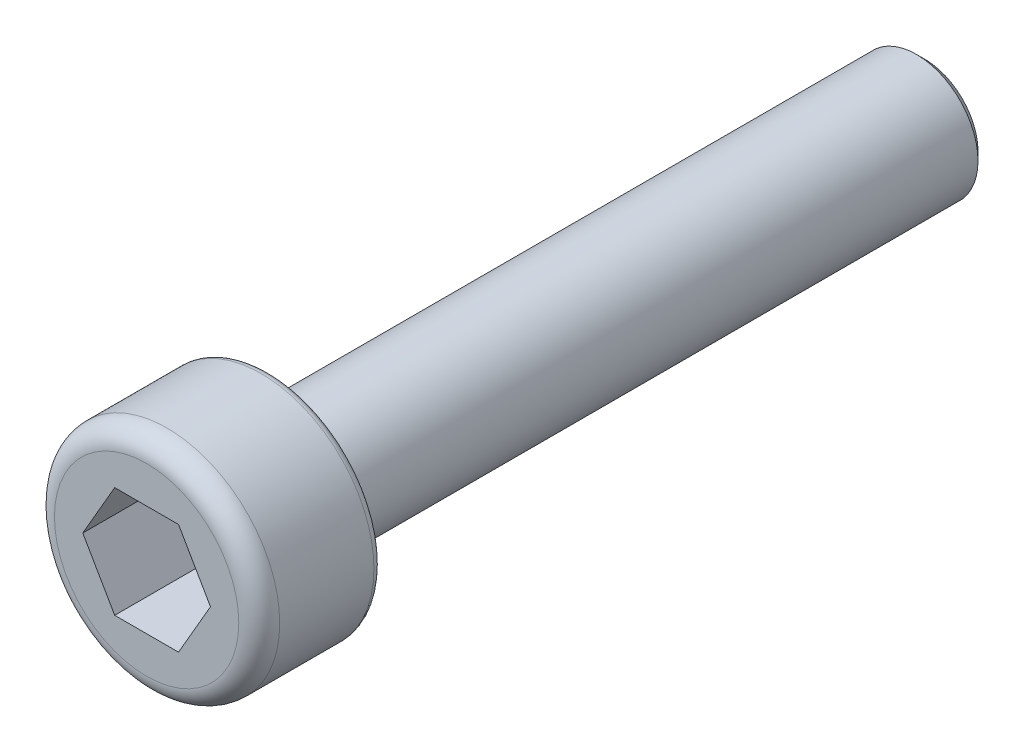
from build123d import *

# Parameters (mm, degrees)
SKETCH_1_R          = 2.75
EXTRUDE_1_DEPTH     = 3
FILLET_1_R          = 0.5
CUT_EXTRUDE_1_DEPTH = 2
SKETCH_3_R          = 1.5
EXTRUDE_2_DEPTH     = 16
CHAMFER_1_SIZE      = 0.2
FILLET_2_R          = 0.2


with BuildPart() as part:
    # 草图1 → 凸台-拉伸1 (new body)
    with BuildSketch(Plane.XY):
        Circle(SKETCH_1_R)
    extrude(amount=EXTRUDE_1_DEPTH)

    # 圆角1
    fillet_1_edges = [part.edges().sort_by_distance(p)[0] for p in [
        (-2.75, 0, 3),
    ]]
    fillet(fillet_1_edges, radius=FILLET_1_R)

    # 草图2 → 切除-拉伸1 (cut)
    with BuildSketch(Plane.XY.offset(3)):
        Polygon((1.558845727, 0), (0.779422863, 1.35), (-0.779422863, 1.35), (-1.558845727, 0), (-0.779422863, -1.35), (0.779422863, -1.35), align=None)
    extrude(amount=-CUT_EXTRUDE_1_DEPTH, mode=Mode.SUBTRACT)

    # 草图3 → 凸台-拉伸2 (add)
    with BuildSketch(Plane(origin=(0, 0, 0), x_dir=(-1, 0, 0), z_dir=(0, 0, -1))):
        Circle(SKETCH_3_R)
    extrude(amount=EXTRUDE_2_DEPTH)

    # 倒角1
    chamfer_1_edges = [part.edges().sort_by_distance(p)[0] for p in [
        (1.5, 0, -16),
    ]]
    chamfer(chamfer_1_edges, length=CHAMFER_1_SIZE)

    # 圆角2
    fillet_2_edges = [part.edges().sort_by_distance(p)[0] for p in [
        (-2.75, 0, 0),
    ]]
    fillet(fillet_2_edges, radius=FILLET_2_R)


solid = part.part
